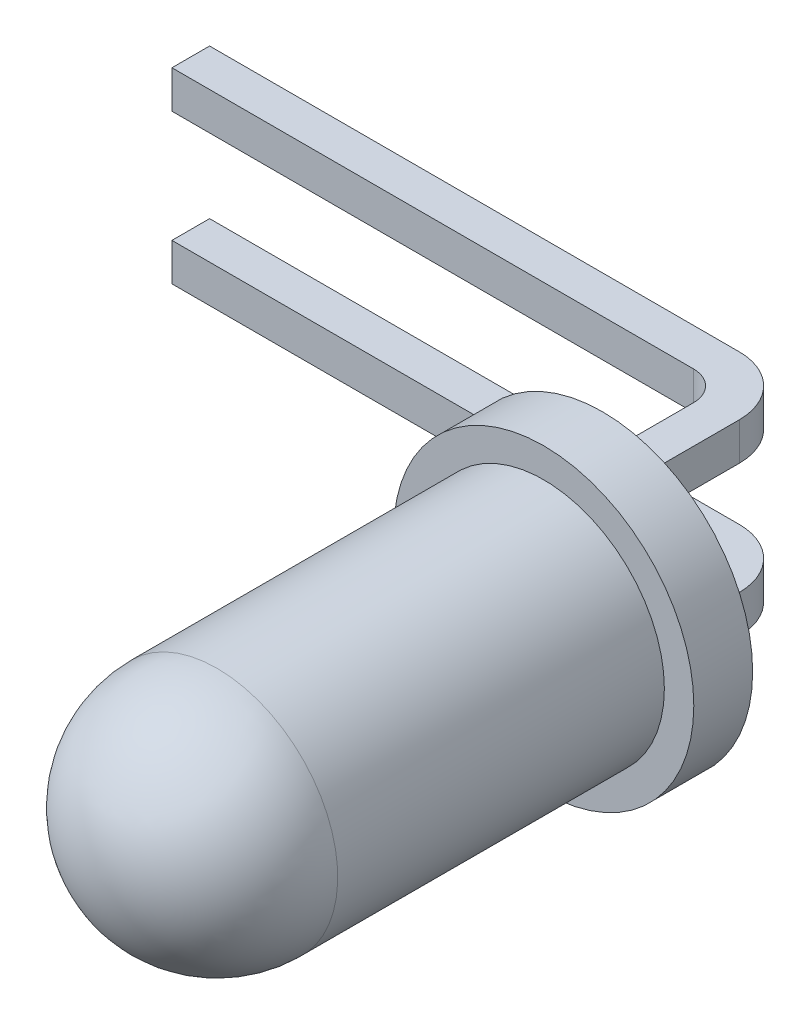
from build123d import *

# Parameters (mm, degrees)
SKETCH3_W           = 0.64
SKETCH3_H           = 0.64
BOSS_EXTRUDE1_DEPTH = 2.683
ESQUISSE1_W         = 0.64
ESQUISSE1_H         = 0.64
BOSS_EXTRU_1_DEPTH  = 10
CONG_1_R            = 1
CONG_1_2_R          = 0.5


with BuildPart() as part:
    # Sketch2 → Base-Revolve (revolve)
    with BuildSketch(Plane(origin=(0, 0, 0), x_dir=(0, 0, -1), z_dir=(1, 0, 0))):
        with BuildLine():
            Line((0, 0), (0, 2.55))
            Line((0, 2.55), (-1, 2.55))
            Line((-1, 2.55), (-1, 2.05))
            Line((-1, 2.05), (-6.55, 2.05))
            ThreePointArc((-6.55, 2.05), (-7.999568901, 1.449568901), (-8.6, 0))
            Line((-8.6, 0), (0, 0))
        make_face()
    revolve(axis=Axis((0, 0, 0), (0, 0, 1)))

    # Sketch3 → Boss-Extrude1 (add)
    with BuildSketch(Plane(origin=(0, 0, 0), x_dir=(-1, 0, 0), z_dir=(0, 0, -1))):
        with Locations((0, 1.27)):
            Rectangle(SKETCH3_W, SKETCH3_H)
        with Locations((0, -1.27)):
            Rectangle(SKETCH3_W, SKETCH3_H)
    extrude(amount=BOSS_EXTRUDE1_DEPTH)

    # Esquisse1 → Boss.-Extru.1 (add)
    with BuildSketch(Plane(origin=(0.32, 0, 0), x_dir=(0, 0, -1), z_dir=(1, 0, 0))):
        with Locations((2.683, -1.27)):
            Rectangle(ESQUISSE1_W, ESQUISSE1_H)
        with Locations((2.683, 1.27)):
            Rectangle(ESQUISSE1_W, ESQUISSE1_H)
    extrude(amount=-BOSS_EXTRU_1_DEPTH)

    # Cong_1
    cong_1_edges = [part.edges().sort_by_distance(p)[0] for p in [
        (0.32, -1.27, -3.003),
        (0.32, 1.27, -3.003),
    ]]
    fillet(cong_1_edges, radius=CONG_1_R)

    # Cong_1 2
    cong_1_2_edges = [part.edges().sort_by_distance(p)[0] for p in [
        (-0.32, 1.27, -2.363),
        (-0.32, -1.27, -2.363),
    ]]
    fillet(cong_1_2_edges, radius=CONG_1_2_R)


solid = part.part
